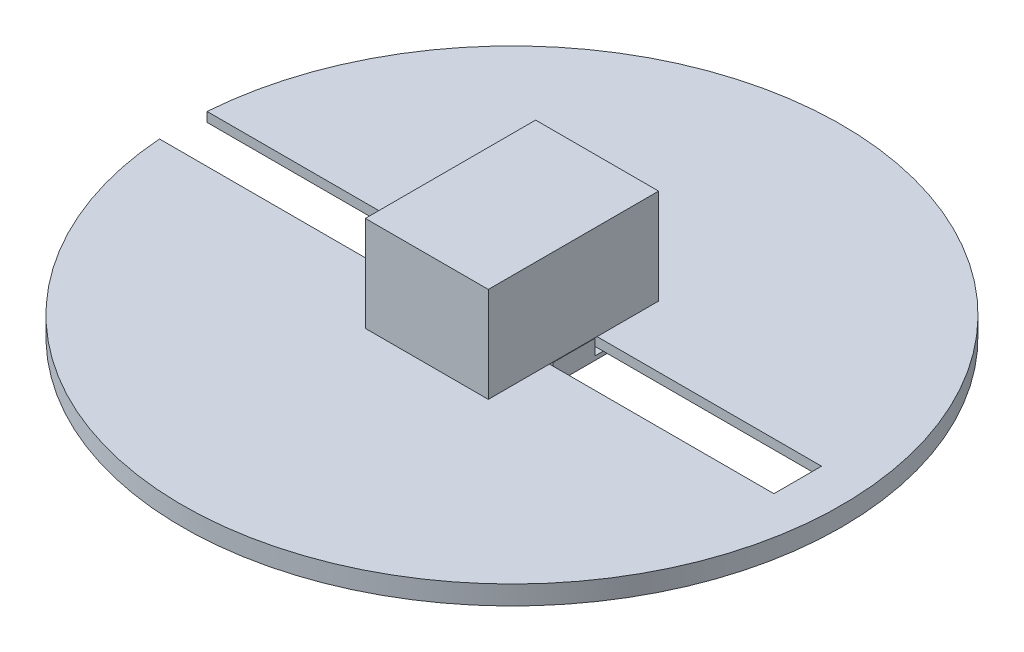
from build123d import *

# Parameters (mm, degrees)
SKETCH1_R                = 34.6
BOSS_EXTRUDE1_DEPTH      = 2
CUT_EXTRUDE4_DEPTH       = 22
CUT_EXTRUDE4_DEPTH_BACK  = 21
CUT_EXTRUDE8_DEPTH       = 30
CUT_EXTRUDE8_DEPTH_BACK  = 38
SKETCH23_W               = 4.4
SKETCH23_H               = 0.6
BOSS_EXTRUDE7_DEPTH      = 6.5
BOSS_EXTRUDE7_DEPTH_BACK = 6.5
SKETCH112_W              = 12.913625174
SKETCH112_H              = 17.880404088
BOSS_EXTRUDE9_DEPTH      = 10


with BuildPart() as part:
    # Sketch1 → Boss-Extrude1 (new body)
    with BuildSketch(Plane(origin=(0, 0, 0), x_dir=(1, 0, 0), z_dir=(0, 1, 0))):
        with Locations(Location((0, 0, 0), (0, 0, 270))):
            Circle(SKETCH1_R)
        Polygon((2.854751228, -2.25), (0, 5.743303437), (-2.854751228, -2.25), align=None, mode=Mode.SUBTRACT)
        Polygon((-2.854751228, -2.25), (2.854751228, -2.25), (0, 5.743303437), align=None)
        with BuildLine():
            Line((-32.964631098, -10.511569654), (-32.964631098, 10.511569654))
            ThreePointArc((-32.964631098, 10.511569654), (-34.6, 0), (-32.964631098, -10.511569654))
        make_face()
    extrude(amount=BOSS_EXTRUDE1_DEPTH)

    # Sketch7 → Cut-Extrude4 (cut, two sides)
    with BuildSketch(Plane.XY) as cut_extrude4_sk:
        Polygon((-34.6, 1), (-29.75, 0), (-34.6, 0), align=None)
    extrude(amount=CUT_EXTRUDE4_DEPTH, mode=Mode.SUBTRACT)
    extrude(cut_extrude4_sk.sketch, amount=-CUT_EXTRUDE4_DEPTH_BACK, mode=Mode.SUBTRACT)

    # Sketch22 → Cut-Extrude8 (cut, two sides)
    with BuildSketch(Plane(origin=(0, 0, 0), x_dir=(0, 0, -1), z_dir=(1, 0, 0))) as cut_extrude8_sk:
        Polygon((-2.5, 2), (-2.5, 1), (-7.5, 1), (-7.5, 0), (7.5, 0), (7.5, 1), (2.5, 1), (2.5, 2), align=None)
    extrude(amount=CUT_EXTRUDE8_DEPTH, mode=Mode.SUBTRACT)
    extrude(cut_extrude8_sk.sketch, amount=-CUT_EXTRUDE8_DEPTH_BACK, mode=Mode.SUBTRACT)


with BuildPart() as body_2:
    # Sketch23 → Boss-Extrude7 (new, two sides)
    with BuildSketch(Plane(origin=(0, 0, 0), x_dir=(0, 0, -1), z_dir=(1, 0, 0))) as boss_extrude7_sk:
        Polygon((7.2, 0), (7.2, 0.421640963), (2.2, 0.421640963), (2.2, 1.421640963), (-2.2, 1.421640963), (-2.2, 0.421640963), (-7.2, 0.421640963), (-7.2, 0), align=None)
        with Locations((0, 1.721640963)):
            Rectangle(SKETCH23_W, SKETCH23_H)
    extrude(amount=BOSS_EXTRUDE7_DEPTH)
    extrude(boss_extrude7_sk.sketch, amount=-BOSS_EXTRUDE7_DEPTH_BACK)

    # Sketch112 → Boss-Extrude9 (add)
    with BuildSketch(Plane(origin=(0, 2.021640963, 0), x_dir=(1, 0, 0), z_dir=(0, 1, 0))):
        Rectangle(SKETCH112_W, SKETCH112_H)
    extrude(amount=BOSS_EXTRUDE9_DEPTH)


solid = Compound([part.part, body_2.part])
